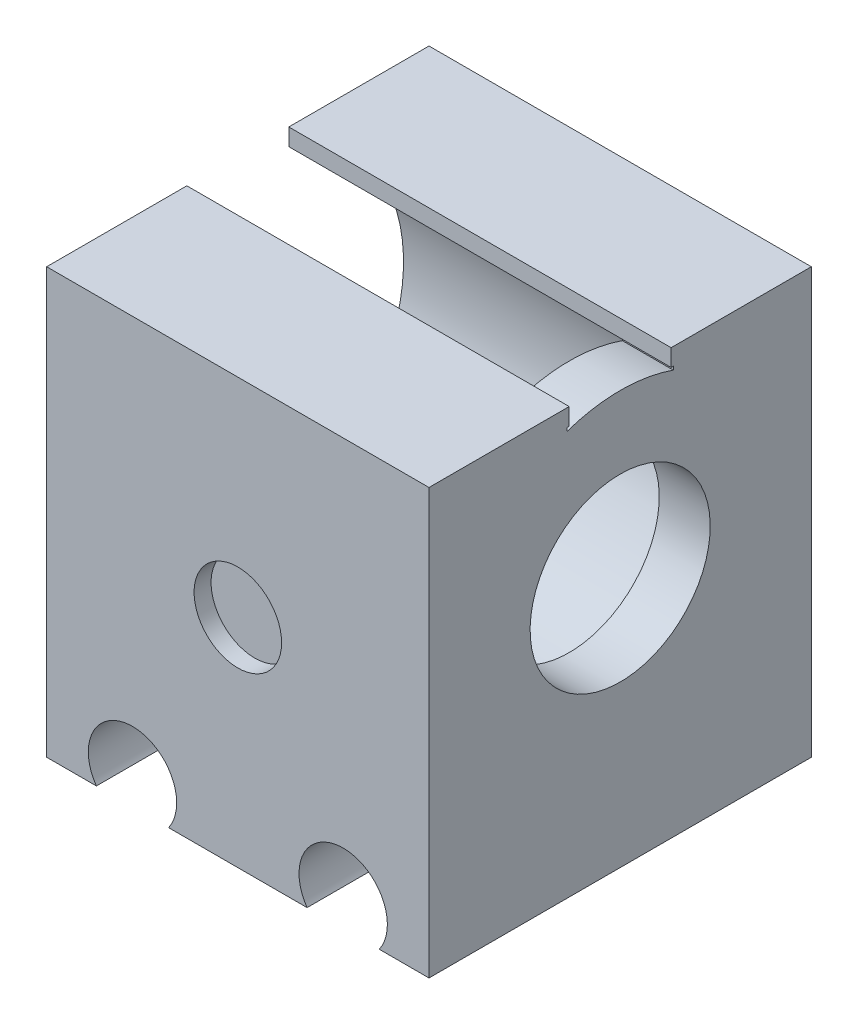
from build123d import *

# Parameters (mm, degrees)
SKETCH1_W           = 45
SKETCH1_H           = 50
BOSS_EXTRUDE1_DEPTH = 45
SKETCH2_R           = 5.2
CUT_EXTRUDE1_DEPTH  = 45
SKETCH3_R           = 19.125
CUT_EXTRUDE2_DEPTH  = 45
SKETCH4_W           = 12.5
SKETCH4_H           = 4.851403087
CUT_EXTRUDE3_DEPTH  = 45
SKETCH5_R           = 19.125
BOSS_EXTRUDE2_DEPTH = 6
SKETCH6_R           = 10.6
CUT_EXTRUDE4_DEPTH  = 6
SKETCH7_R           = 19.5
CUT_EXTRUDE5_DEPTH  = 39
SKETCH8_W           = 0.25
SKETCH8_H           = 2.013794316
BOSS_EXTRUDE3_DEPTH = 45
SKETCH9_R           = 5.15
CUT_EXTRUDE6_DEPTH  = 2
SKETCH10_R          = 5.15
CUT_EXTRUDE7_DEPTH  = 2


with BuildPart() as part:
    # Sketch1 → Boss-Extrude1 (new body)
    with BuildSketch(Plane.XY):
        with Locations((8.236607143, -2.901785714)):
            Rectangle(SKETCH1_W, SKETCH1_H)
    extrude(amount=BOSS_EXTRUDE1_DEPTH)

    # Sketch2 → Cut-Extrude1 (cut)
    with BuildSketch(Plane.XY.offset(45)):
        with Locations((-4.163392857, -24.901785714)):
            Circle(SKETCH2_R)
        with Locations((20.636607143, -24.901785714)):
            Circle(SKETCH2_R)
    extrude(amount=-CUT_EXTRUDE1_DEPTH, mode=Mode.SUBTRACT)

    # Sketch3 → Cut-Extrude2 (cut)
    with BuildSketch(Plane(origin=(30.736607143, 0, 0), x_dir=(0, 0, -1), z_dir=(1, 0, 0))):
        with Locations((-22.5, 1.613158508)):
            Circle(SKETCH3_R)
    extrude(amount=-CUT_EXTRUDE2_DEPTH, mode=Mode.SUBTRACT)

    # Sketch4 → Cut-Extrude3 (cut)
    with BuildSketch(Plane(origin=(30.736607143, 0, 0), x_dir=(0, 0, -1), z_dir=(1, 0, 0))):
        with Locations((-22.5, 20.946020309)):
            Rectangle(SKETCH4_W, SKETCH4_H)
    extrude(amount=-CUT_EXTRUDE3_DEPTH, mode=Mode.SUBTRACT)

    # Sketch5 → Boss-Extrude2 (add)
    with BuildSketch(Plane(origin=(30.736607143, 0, 0), x_dir=(0, 0, -1), z_dir=(1, 0, 0))):
        with Locations((-22.5, 1.613158508)):
            Circle(SKETCH5_R)
    extrude(amount=-BOSS_EXTRUDE2_DEPTH)

    # Sketch6 → Cut-Extrude4 (cut)
    with BuildSketch(Plane(origin=(30.736607143, 0, 0), x_dir=(0, 0, -1), z_dir=(1, 0, 0))):
        with Locations((-22.5, 1.613158508)):
            Circle(SKETCH6_R)
    extrude(amount=-CUT_EXTRUDE4_DEPTH, mode=Mode.SUBTRACT)

    # Sketch7 → Cut-Extrude5 (cut)
    with BuildSketch(Plane.ZY.offset(14.263392857)):
        with Locations((22.5, 1.613158508)):
            Circle(SKETCH7_R)
    extrude(amount=-CUT_EXTRUDE5_DEPTH, mode=Mode.SUBTRACT)

    # Sketch8 → Boss-Extrude3 (add)
    with BuildSketch(Plane.ZY.offset(14.263392857)):
        with Locations((16.375, 21.091317128)):
            Rectangle(SKETCH8_W, SKETCH8_H)
        with Locations((28.625, 21.091317128)):
            Rectangle(SKETCH8_W, SKETCH8_H)
    extrude(amount=-BOSS_EXTRUDE3_DEPTH)

    # Sketch9 → Cut-Extrude6 (cut)
    with BuildSketch(Plane.XY.offset(45)):
        with Locations((8.236607143, -2.401785714)):
            Circle(SKETCH9_R)
    extrude(amount=-CUT_EXTRUDE6_DEPTH, mode=Mode.SUBTRACT)

    # Sketch10 → Cut-Extrude7 (cut)
    with BuildSketch(Plane(origin=(0, 0, 0), x_dir=(-1, 0, 0), z_dir=(0, 0, -1))):
        with Locations((-8.236607143, -2.401785714)):
            Circle(SKETCH10_R)
    extrude(amount=-CUT_EXTRUDE7_DEPTH, mode=Mode.SUBTRACT)


solid = part.part
